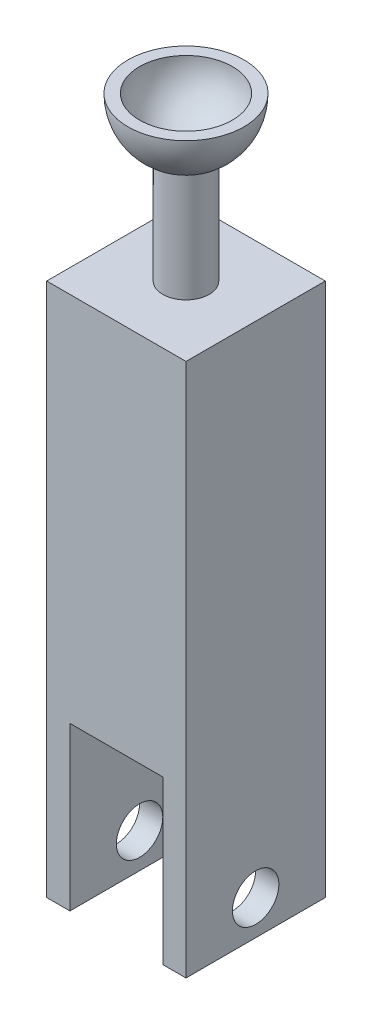
from build123d import *

# Parameters (mm, degrees)
CROQUIS1_W                 = 60
CROQUIS1_H                 = 60
SALIENTE_EXTRUIR1_DEPTH    = 300
CROQUIS2_W                 = 40
CROQUIS2_H                 = 70
CORTAR_EXTRUIR1_DEPTH      = 31
CORTAR_EXTRUIR1_DEPTH_BACK = 31
CROQUIS3_R                 = 10
CORTAR_EXTRUIR2_DEPTH      = 31
CORTAR_EXTRUIR2_DEPTH_BACK = 31


with BuildPart() as part:
    # Croquis1 → Saliente-Extruir1 (new body)
    with BuildSketch(Plane(origin=(0, 0, 0), x_dir=(1, 0, 0), z_dir=(0, 1, 0))):
        Rectangle(CROQUIS1_W, CROQUIS1_H)
    extrude(amount=SALIENTE_EXTRUIR1_DEPTH)

    # Croquis2 → Cortar-Extruir1 (cut, two sides)
    with BuildSketch(Plane.XY) as cortar_extruir1_sk:
        with Locations((0, 35)):
            Rectangle(CROQUIS2_W, CROQUIS2_H)
    extrude(amount=CORTAR_EXTRUIR1_DEPTH, mode=Mode.SUBTRACT)
    extrude(cortar_extruir1_sk.sketch, amount=-CORTAR_EXTRUIR1_DEPTH_BACK, mode=Mode.SUBTRACT)

    # Croquis3 → Cortar-Extruir2 (cut, two sides)
    with BuildSketch(Plane(origin=(0, 0, 0), x_dir=(0, 0, -1), z_dir=(1, 0, 0))) as cortar_extruir2_sk:
        with Locations((0, 15)):
            Circle(CROQUIS3_R)
    extrude(amount=CORTAR_EXTRUIR2_DEPTH, mode=Mode.SUBTRACT)
    extrude(cortar_extruir2_sk.sketch, amount=-CORTAR_EXTRUIR2_DEPTH_BACK, mode=Mode.SUBTRACT)

    # Croquis4 → Cortar-Revolución5 (revolve, cut)
    with BuildSketch(Plane.XY):
        with BuildLine():
            ThreePointArc((-25, 300), (-20.916500663, 286.306936062), (-10, 277.087121525))
            Line((-10, 277.087121525), (-10, 230))
            Line((-10, 230), (-30, 230))
            Line((-30, 230), (-59.400541748, 230))
            Line((-59.400541748, 230), (-59.400541748, 300))
            Line((-59.400541748, 300), (-25, 300))
        make_face()
        with BuildLine():
            Line((0, 300), (-20, 300))
            ThreePointArc((-20, 300), (-14.142135624, 285.857864376), (0, 280))
            Line((0, 280), (0, 300))
        make_face()
    revolve(axis=Axis((0, 300, 0), (0, -1, 0)), mode=Mode.SUBTRACT)


solid = part.part
